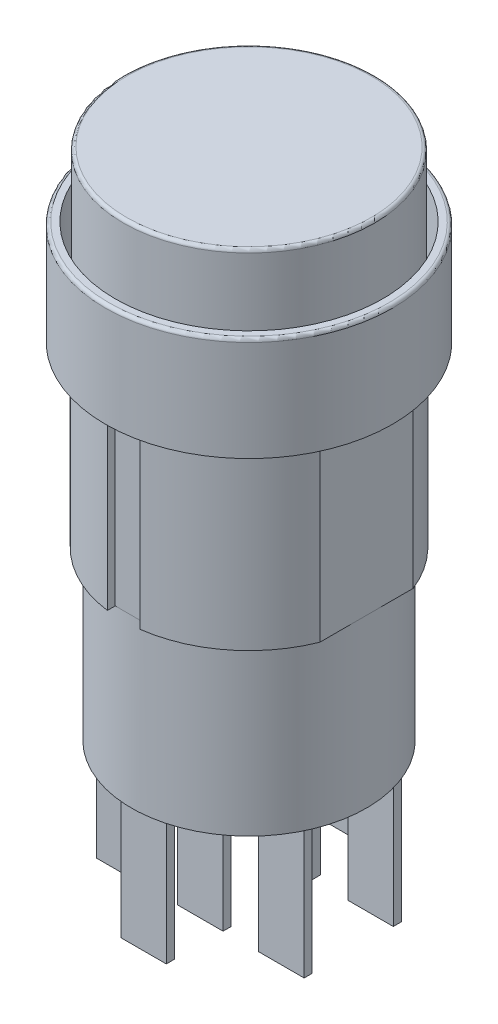
from build123d import *

# Parameters (mm, degrees)
ESBO_O2_R                = 8.85
RESSALTO_EXTRUS_O1_DEPTH = 6.4
ESBO_O3_R                = 8.25
CORTE_EXTRUS_O1_DEPTH    = 5
ESBO_O4_R                = 7.75
RESSALTO_EXTRUS_O2_DEPTH = 9
FILETE1_R                = 0.2
ESBO_O5_R                = 7.8
RESSALTO_EXTRUS_O3_DEPTH = 11
ESBO_O6_R                = 7.25
RESSALTO_EXTRUS_O4_DEPTH = 10.3
ESBO_O7_W                = 21.473826642
ESBO_O7_H                = 23.10287556
CORTE_EXTRUS_O2_DEPTH    = 11
ESBO_O8_W                = 2.8
ESBO_O8_H                = 0.5
RESSALTO_EXTRUS_O5_DEPTH = 8


with BuildPart() as part:
    # Esboço2 → Ressalto-extrusão1 (new body)
    with BuildSketch(Plane(origin=(0, 0, 0), x_dir=(1, 0, 0), z_dir=(0, 1, 0))):
        Circle(ESBO_O2_R)
    extrude(amount=RESSALTO_EXTRUS_O1_DEPTH)

    # Esboço3 → Corte-extrusão1 (cut)
    with BuildSketch(Plane(origin=(0, 6.4, 0), x_dir=(1, 0, 0), z_dir=(0, 1, 0))):
        Circle(ESBO_O3_R)
    extrude(amount=-CORTE_EXTRUS_O1_DEPTH, mode=Mode.SUBTRACT)

    # Esboço4 → Ressalto-extrusão2 (add)
    with BuildSketch(Plane(origin=(0, 1.4, 0), x_dir=(1, 0, 0), z_dir=(0, 1, 0))):
        Circle(ESBO_O4_R)
    extrude(amount=RESSALTO_EXTRUS_O2_DEPTH)

    # Filete1
    filete1_edges = [part.edges().sort_by_distance(p)[0] for p in [
        (-7.75, 10.4, 0),
        (-8.85, 6.4, 0),
    ]]
    fillet(filete1_edges, radius=FILETE1_R)

    # Esboço5 → Ressalto-extrusão3 (add)
    with BuildSketch(Plane.XZ):
        Circle(ESBO_O5_R)
    extrude(amount=RESSALTO_EXTRUS_O3_DEPTH)

    # Esboço6 → Ressalto-extrusão4 (add)
    with BuildSketch(Plane.XZ.offset(11)):
        Circle(ESBO_O6_R)
    extrude(amount=RESSALTO_EXTRUS_O4_DEPTH)

    # Esboço7 → Corte-extrusão2 (cut)
    with BuildSketch(Plane.XZ.offset(11)):
        Rectangle(ESBO_O7_W, ESBO_O7_H)
        Polygon((-7.25, -7.8), (-1, -7.8), (-1, -7.25), (1, -7.25), (1, -7.8), (7.25, -7.8), (7.25, 7.8), (1, 7.8), (1, 7.25), (-1, 7.25), (-1, 7.8), (-7.25, 7.8), align=None, mode=Mode.SUBTRACT)
    extrude(amount=-CORTE_EXTRUS_O2_DEPTH, mode=Mode.SUBTRACT)

    # Esboço8 → Ressalto-extrusão5 (add)
    with BuildSketch(Plane.XZ.offset(21.3)):
        with Locations((-5, 2.75)):
            Rectangle(ESBO_O8_W, ESBO_O8_H)
        with Locations((0, 2.75)):
            Rectangle(ESBO_O8_W, ESBO_O8_H)
        with Locations((5, 2.75)):
            Rectangle(ESBO_O8_W, ESBO_O8_H)
        with Locations((0, 6.25)):
            Rectangle(ESBO_O8_W, ESBO_O8_H)
        with Locations((0, -6.25)):
            Rectangle(ESBO_O8_W, ESBO_O8_H)
        with Locations((5, -2.75)):
            Rectangle(ESBO_O8_W, ESBO_O8_H)
        with Locations((0, -2.75)):
            Rectangle(ESBO_O8_W, ESBO_O8_H)
        with Locations((-5, -2.75)):
            Rectangle(ESBO_O8_W, ESBO_O8_H)
    extrude(amount=RESSALTO_EXTRUS_O5_DEPTH)


solid = part.part
